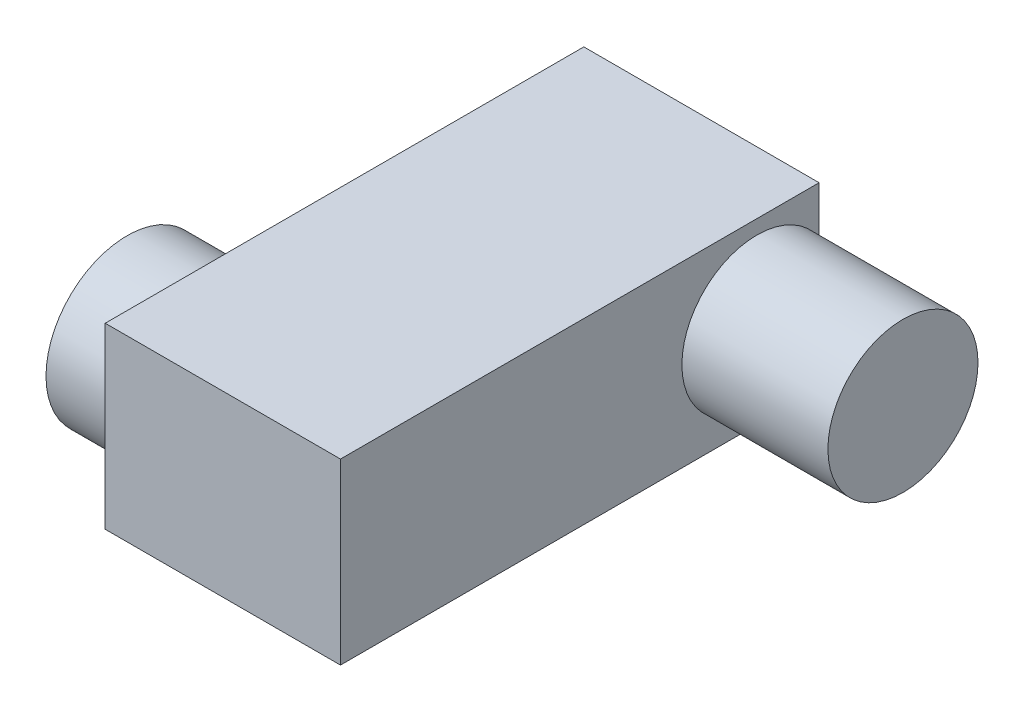
from build123d import *

# Parameters (mm, degrees)
SKETCH1_W           = 29
SKETCH1_H           = 59
BOSS_EXTRUDE1_DEPTH = 22
SKETCH4_R           = 9.25
BOSS_EXTRUDE4_DEPTH = 18
SKETCH5_R           = 10
BOSS_EXTRUDE5_DEPTH = 9


with BuildPart() as part:
    # Sketch1 → Boss-Extrude1 (new body)
    with BuildSketch(Plane(origin=(0, 0, 0), x_dir=(1, 0, 0), z_dir=(0, 1, 0))):
        with Locations((-14.5, 29.5)):
            Rectangle(SKETCH1_W, SKETCH1_H)
    extrude(amount=BOSS_EXTRUDE1_DEPTH)

    # Sketch4 → Boss-Extrude4 (add)
    with BuildSketch(Plane(origin=(0, 0, 0), x_dir=(0, 0, -1), z_dir=(1, 0, 0))):
        with Locations((51.3375, 11)):
            Circle(SKETCH4_R)
    extrude(amount=BOSS_EXTRUDE4_DEPTH)

    # Sketch5 → Boss-Extrude5 (add)
    with BuildSketch(Plane.ZY.offset(29)):
        with Locations((-11.7, 11)):
            Circle(SKETCH5_R)
    extrude(amount=BOSS_EXTRUDE5_DEPTH)


solid = part.part
